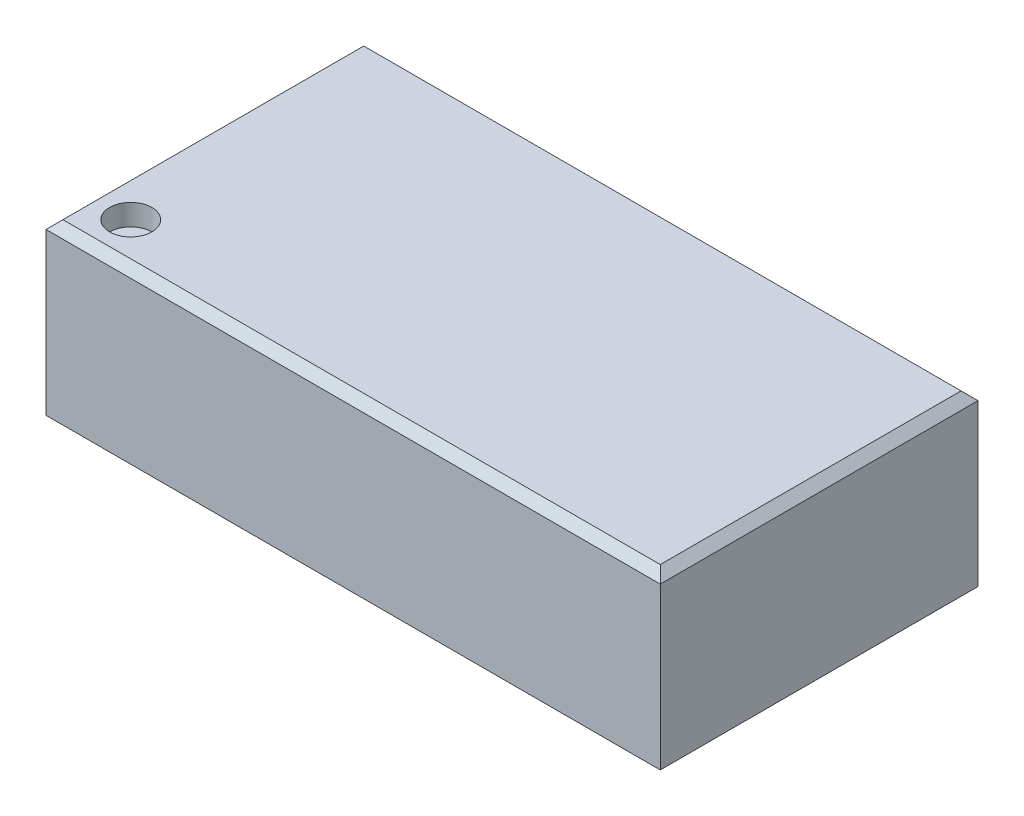
from build123d import *

# Parameters (mm, degrees)
ESQUISSE1_W             = 7.25
ESQUISSE1_H             = 3.75
BOSS_EXTRU_1_DEPTH      = 2
ESQUISSE2_R             = 0.25
ENL_V_MAT_EXTRU_1_DEPTH = 0.25
CHANFREIN1_SIZE         = 0.1


with BuildPart() as part:
    # Esquisse1 → Boss.-Extru.1 (new body)
    with BuildSketch(Plane(origin=(0, 0, 0), x_dir=(1, 0, 0), z_dir=(0, 1, 0))):
        Rectangle(ESQUISSE1_W, ESQUISSE1_H)
    extrude(amount=BOSS_EXTRU_1_DEPTH)

    # Esquisse2 → Enlèv. mat.-Extru.1 (cut)
    with BuildSketch(Plane(origin=(0, 2, 0), x_dir=(1, 0, 0), z_dir=(0, 1, 0))):
        with Locations(Location((-3.125, -1.375, 0), (0, 0, 270))):  # turned: the seam where the file's is
            Circle(ESQUISSE2_R)
    extrude(amount=-ENL_V_MAT_EXTRU_1_DEPTH, mode=Mode.SUBTRACT)

    # Chanfrein1
    chanfrein1_edges = [part.edges().sort_by_distance(p)[0] for p in [
        (3.625, 2, 0),
        (0, 2, -1.875),
        (-3.625, 2, 0),
        (0, 2, 1.875),
    ]]
    chamfer(chanfrein1_edges, length=CHANFREIN1_SIZE)


solid = part.part
